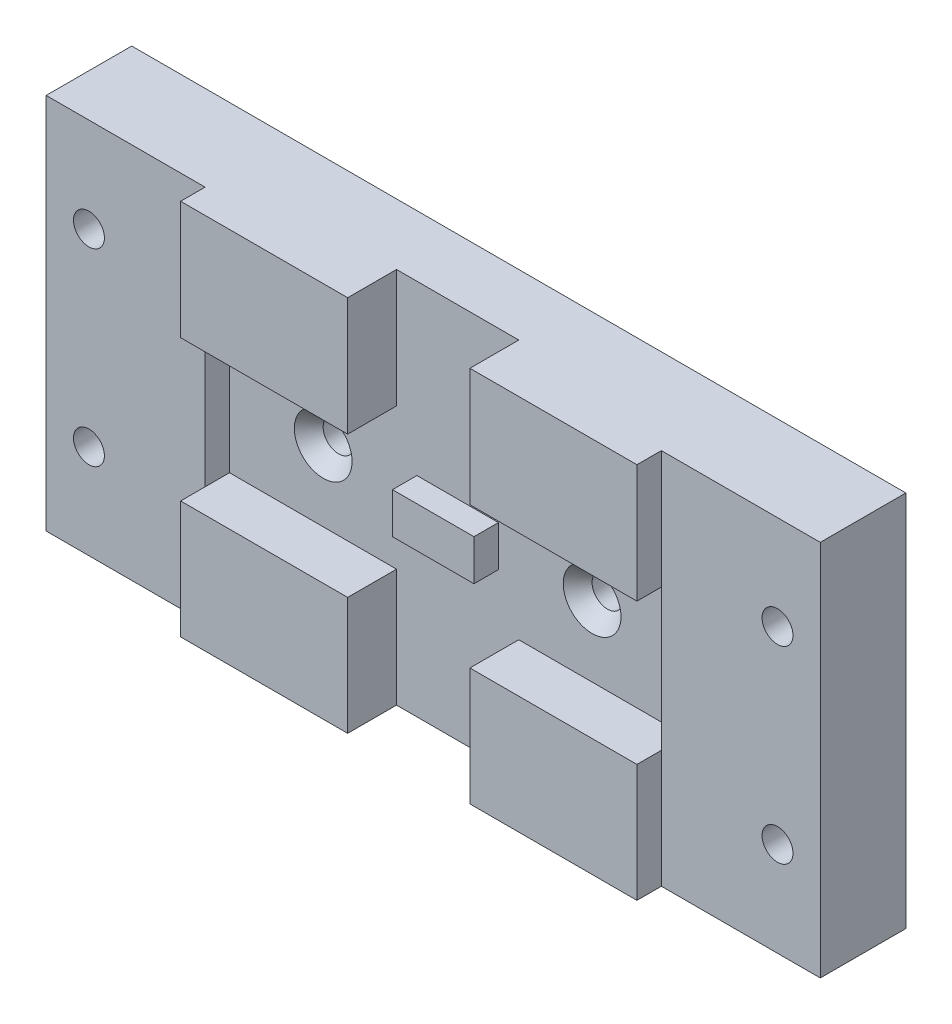
from build123d import *

# Parameters (mm, degrees)
SKETCH2_W                                      = 95
SKETCH2_H                                      = 46.3
BOSS_EXTRUDE1_DEPTH                            = 7.5
SKETCH3_W                                      = 10
SKETCH3_H                                      = 5
SKETCH3_W_2                                    = 19.5
SKETCH3_H_2                                    = 46.3
BOSS_EXTRUDE2_DEPTH                            = 3
SKETCH4_W                                      = 56
SKETCH4_H                                      = 15
SKETCH4_W_2                                    = 20.5
BOSS_EXTRUDE3_DEPTH                            = 6
CSK_FOR_6_FLAT_HEAD_MACHINE_SCREW1_D           = 3.7973
CSK_FOR_6_FLAT_HEAD_MACHINE_SCREW1_CSINK_D     = 7.0866
CSK_FOR_6_FLAT_HEAD_MACHINE_SCREW1_CSINK_ANGLE = 82
CSK_FOR_6_FLAT_HEAD_MACHINE_SCREW2_D           = 3.7973
CSK_FOR_6_FLAT_HEAD_MACHINE_SCREW2_CSINK_D     = 7.0866
CSK_FOR_6_FLAT_HEAD_MACHINE_SCREW2_CSINK_ANGLE = 82
SKETCH18_W                                     = 15
SKETCH18_H                                     = 25.808879712
CUT_EXTRUDE4_DEPTH                             = 6
SKETCH19_W                                     = 20.5
SKETCH19_H                                     = 6
CUT_EXTRUDE5_DEPTH                             = 16.85
CUT_EXTRUDE5_DEPTH_BACK                        = 0.5


with BuildPart() as part:
    # Sketch2 → Boss-Extrude1 (new body)
    with BuildSketch(Plane.XY):
        Rectangle(SKETCH2_W, SKETCH2_H)
    extrude(amount=-BOSS_EXTRUDE1_DEPTH)

    # Sketch3 → Boss-Extrude2 (add)
    with BuildSketch(Plane.XY):
        Rectangle(SKETCH3_W, SKETCH3_H)
        with Locations((37.75, 0)):
            Rectangle(SKETCH3_W_2, SKETCH3_H_2)
        with Locations((-37.75, 0)):
            Rectangle(SKETCH3_W_2, SKETCH3_H_2)
    extrude(amount=BOSS_EXTRUDE2_DEPTH)

    # Sketch4 → Boss-Extrude3 (add)
    with BuildSketch(Plane.XY):
        with Locations((0, -15.65)):
            Rectangle(SKETCH4_W, SKETCH4_H)
        with Locations((17.75, 15.65)):
            Rectangle(SKETCH4_W_2, SKETCH4_H)
        with Locations((-17.75, 15.65)):
            Rectangle(SKETCH4_W_2, SKETCH4_H)
    extrude(amount=BOSS_EXTRUDE3_DEPTH)

    # CSK for #6 Flat Head Machine Screw1 (through all)
    with Locations(Plane.XY):
        with Locations((16.5, 0), (-16.5, 0)):
            CounterSinkHole(CSK_FOR_6_FLAT_HEAD_MACHINE_SCREW1_D / 2, CSK_FOR_6_FLAT_HEAD_MACHINE_SCREW1_CSINK_D / 2, counter_sink_angle=CSK_FOR_6_FLAT_HEAD_MACHINE_SCREW1_CSINK_ANGLE)

    # CSK for #6 Flat Head Machine Screw2 (through all)
    with Locations(Plane(origin=(0, 0, -7.5), x_dir=(-1, 0, 0), z_dir=(0, 0, -1))):
        with Locations((42.25, 11.575), (42.25, -11.575), (-42.25, 11.575), (-42.25, -11.575)):
            CounterSinkHole(CSK_FOR_6_FLAT_HEAD_MACHINE_SCREW2_D / 2, CSK_FOR_6_FLAT_HEAD_MACHINE_SCREW2_CSINK_D / 2, counter_sink_angle=CSK_FOR_6_FLAT_HEAD_MACHINE_SCREW2_CSINK_ANGLE)

    # Sketch18 → Cut-Extrude4 (cut)
    with BuildSketch(Plane.XY):
        with Locations((0, -19.186864523)):
            Rectangle(SKETCH18_W, SKETCH18_H)
    extrude(amount=CUT_EXTRUDE4_DEPTH, mode=Mode.SUBTRACT)

    # Sketch19 → Cut-Extrude5 (cut, two sides)
    with BuildSketch(Plane.XZ.offset(-8.15)) as cut_extrude5_sk:
        with Locations((-17.75, 3)):
            Rectangle(SKETCH19_W, SKETCH19_H)
        with Locations((17.75, 3)):
            Rectangle(SKETCH19_W, SKETCH19_H)
    extrude(amount=CUT_EXTRUDE5_DEPTH, mode=Mode.SUBTRACT)
    extrude(cut_extrude5_sk.sketch, amount=-CUT_EXTRUDE5_DEPTH_BACK, mode=Mode.SUBTRACT)


solid = part.part
